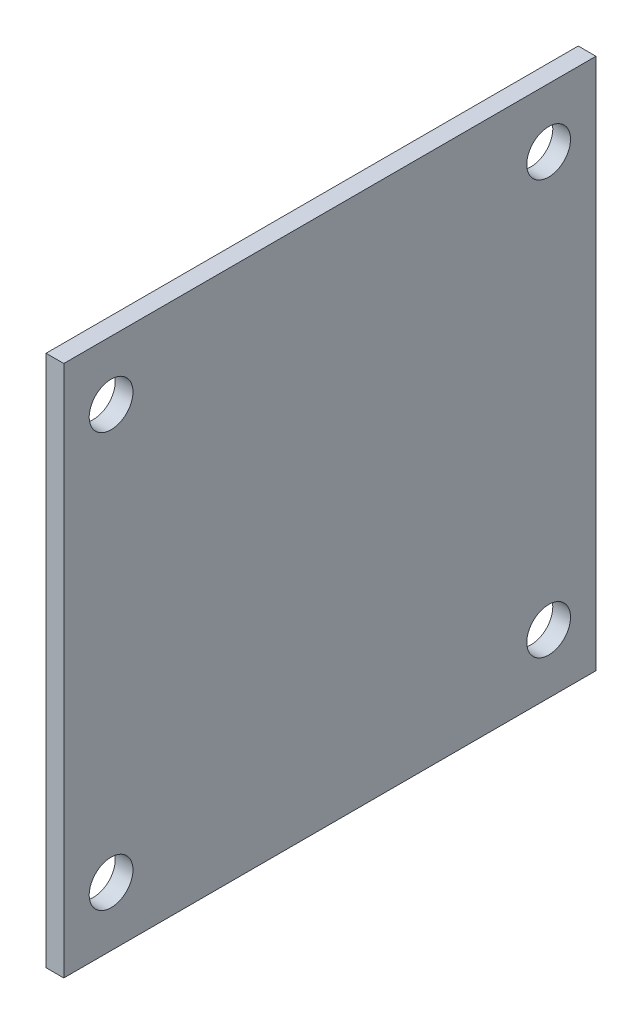
from build123d import *

# Parameters (mm, degrees)
SKETCH1_W           = 45
SKETCH1_H           = 45
BOSS_EXTRUDE1_DEPTH = 1.5
SKETCH2_R           = 1.85
CUT_EXTRUDE1_DEPTH  = 2.5


with BuildPart() as part:
    # Sketch1 → Boss-Extrude1 (new body)
    with BuildSketch(Plane(origin=(0, 0, 0), x_dir=(0, 0, -1), z_dir=(1, 0, 0))):
        Rectangle(SKETCH1_W, SKETCH1_H)
    extrude(amount=BOSS_EXTRUDE1_DEPTH)

    # Sketch2 → Cut-Extrude1 (cut, through all)
    with BuildSketch(Plane(origin=(1.5, 0, 0), x_dir=(0, 0, -1), z_dir=(1, 0, 0))):
        with Locations((-18.5, 17.5)):
            Circle(SKETCH2_R)
        with Locations((-18.5, -17.5)):
            Circle(SKETCH2_R)
        with Locations((18.5, 17.5)):
            Circle(SKETCH2_R)
        with Locations((18.5, -17.5)):
            Circle(SKETCH2_R)
    extrude(amount=-CUT_EXTRUDE1_DEPTH, mode=Mode.SUBTRACT)


solid = part.part
